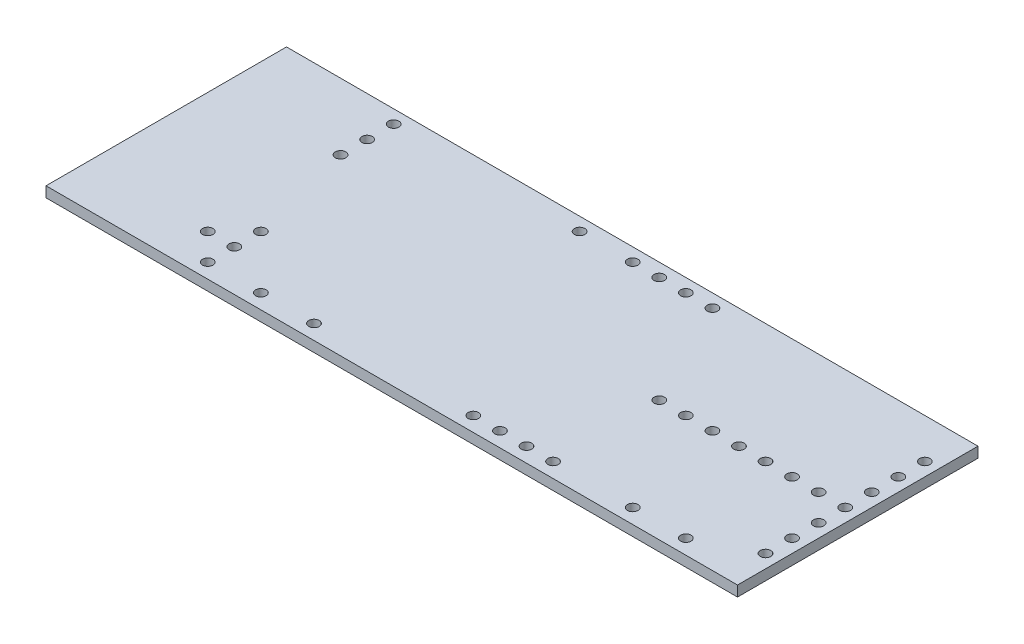
from build123d import *

# Parameters (mm, degrees)
SKETCH1_W           = 58.5
SKETCH1_H           = 23
BOSS_EXTRUDE1_DEPTH = 1
SKETCH2_R           = 0.5
CUT_EXTRUDE1_DEPTH  = 2
SKETCH3_W           = 23
SKETCH3_H           = 1
BOSS_EXTRUDE2_DEPTH = 7.63


with BuildPart() as part:
    # Sketch1 → Boss-Extrude1 (new body)
    with BuildSketch(Plane(origin=(0, 0, 0), x_dir=(1, 0, 0), z_dir=(0, 1, 0))):
        with Locations((29.25, -11.5)):
            Rectangle(SKETCH1_W, SKETCH1_H)
    extrude(amount=BOSS_EXTRUDE1_DEPTH)

    # Sketch2 → Cut-Extrude1 (cut, through all)
    with BuildSketch(Plane(origin=(0, 1, 0), x_dir=(1, 0, 0), z_dir=(0, 1, 0))):
        with Locations((57.23, -3.81)):
            Circle(SKETCH2_R)
        with Locations((57.23, -6.35)):
            Circle(SKETCH2_R)
        with Locations((57.23, -8.89)):
            Circle(SKETCH2_R)
        with Locations((57.23, -11.43)):
            Circle(SKETCH2_R)
        with Locations((57.23, -13.97)):
            Circle(SKETCH2_R)
        with Locations((57.23, -16.51)):
            Circle(SKETCH2_R)
        with Locations((57.23, -19.05)):
            Circle(SKETCH2_R)
        with Locations((54.69, -11.43)):
            Circle(SKETCH2_R)
        with Locations((52.15, -11.43)):
            Circle(SKETCH2_R)
        with Locations((49.61, -11.43)):
            Circle(SKETCH2_R)
        with Locations((47.07, -11.43)):
            Circle(SKETCH2_R)
        with Locations((44.53, -11.43)):
            Circle(SKETCH2_R)
        with Locations((41.99, -11.43)):
            Circle(SKETCH2_R)
        with Locations((39.45, -11.43)):
            Circle(SKETCH2_R)
        with Locations((39.45, -21.59)):
            Circle(SKETCH2_R)
        with Locations((36.91, -21.59)):
            Circle(SKETCH2_R)
        with Locations((34.37, -21.59)):
            Circle(SKETCH2_R)
        with Locations((31.83, -21.59)):
            Circle(SKETCH2_R)
        with Locations((16.59, -21.59)):
            Circle(SKETCH2_R)
        with Locations((11.51, -21.59)):
            Circle(SKETCH2_R)
        with Locations((6.43, -21.59)):
            Circle(SKETCH2_R)
        with Locations((47.07, -21.59)):
            Circle(SKETCH2_R)
        with Locations((52.15, -21.59)):
            Circle(SKETCH2_R)
        with Locations((6.43, -19.05)):
            Circle(SKETCH2_R)
        with Locations((6.43, -16.51)):
            Circle(SKETCH2_R)
        with Locations((3.89, -19.05)):
            Circle(SKETCH2_R)
        with Locations((3.89, -6.35)):
            Circle(SKETCH2_R)
        with Locations((3.89, -3.81)):
            Circle(SKETCH2_R)
        with Locations((3.89, -1.27)):
            Circle(SKETCH2_R)
        with Locations((21.67, -1.27)):
            Circle(SKETCH2_R)
        with Locations((26.75, -1.27)):
            Circle(SKETCH2_R)
        with Locations((29.29, -1.27)):
            Circle(SKETCH2_R)
        with Locations((31.83, -1.27)):
            Circle(SKETCH2_R)
        with Locations((34.37, -1.27)):
            Circle(SKETCH2_R)
    extrude(amount=-CUT_EXTRUDE1_DEPTH, mode=Mode.SUBTRACT)

    # Sketch3 → Boss-Extrude2 (add)
    with BuildSketch(Plane.ZY):
        with Locations((11.5, 0.5)):
            Rectangle(SKETCH3_W, SKETCH3_H)
    extrude(amount=BOSS_EXTRUDE2_DEPTH)


solid = part.part
